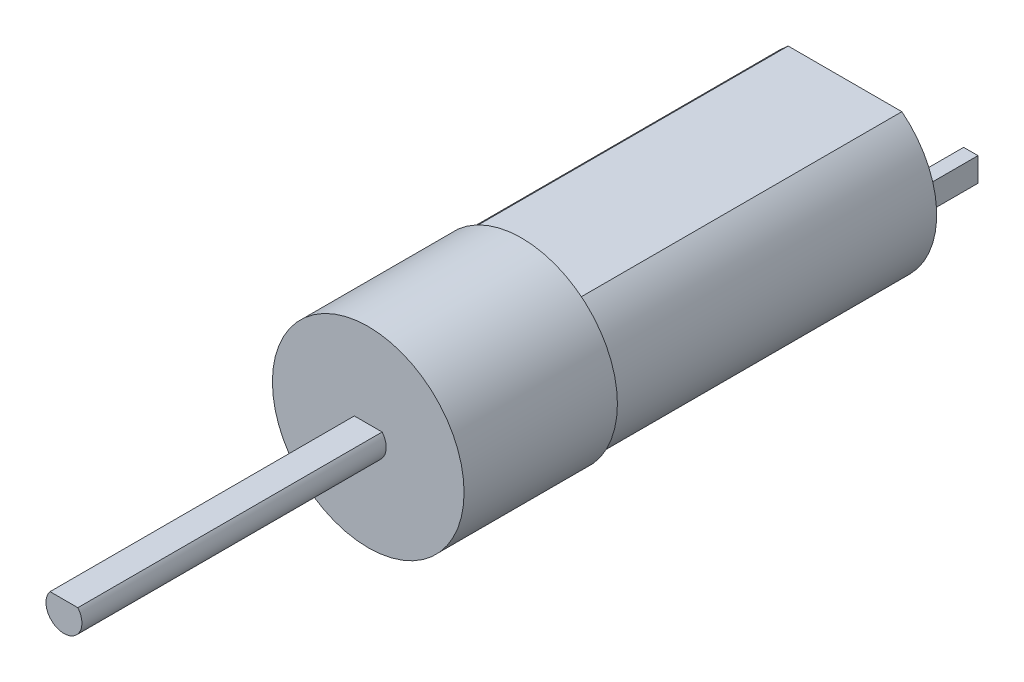
from build123d import *

# Parameters (mm, degrees)
SKETCH1_R           = 8
BOSS_EXTRUDE1_DEPTH = 12.8
SKETCH3_R           = 7.65
BOSS_EXTRUDE3_DEPTH = 27
CUT_EXTRUDE1_DEPTH  = 27
BOSS_EXTRUDE4_DEPTH = 25.4
SKETCH8_W           = 1.2
SKETCH8_H           = 2
BOSS_EXTRUDE5_DEPTH = 5


with BuildPart() as part:
    # Sketch1 → Boss-Extrude1 (new body)
    with BuildSketch(Plane.XY):
        Circle(SKETCH1_R)
    extrude(amount=BOSS_EXTRUDE1_DEPTH)

    # Sketch3 → Boss-Extrude3 (add)
    with BuildSketch(Plane(origin=(0, 0, 0), x_dir=(-1, 0, 0), z_dir=(0, 0, -1))):
        Circle(SKETCH3_R)
    extrude(amount=BOSS_EXTRUDE3_DEPTH)

    # Sketch4 → Cut-Extrude1 (cut)
    with BuildSketch(Plane(origin=(0, 0, -27), x_dir=(-1, 0, 0), z_dir=(0, 0, -1))):
        with BuildLine():
            Line((-4.745787606, -6), (4.745787606, -6))
            ThreePointArc((4.745787606, -6), (0, -7.65), (-4.745787606, -6))
        make_face()
        with BuildLine():
            Line((-4.745787606, 6), (4.745787606, 6))
            ThreePointArc((4.745787606, 6), (0, 7.65), (-4.745787606, 6))
        make_face()
    extrude(amount=-CUT_EXTRUDE1_DEPTH, mode=Mode.SUBTRACT)

    # Sketch7 → Boss-Extrude4 (add)
    with BuildSketch(Plane.XY.offset(12.8)):
        with BuildLine():
            Line((-1.160818677, 0.95), (1.160818677, 0.95))
            ThreePointArc((1.160818677, 0.95), (0, -1.5), (-1.160818677, 0.95))
        make_face()
    extrude(amount=BOSS_EXTRUDE4_DEPTH)

    # Sketch8 → Boss-Extrude5 (add)
    with BuildSketch(Plane(origin=(0, 0, -27), x_dir=(-1, 0, 0), z_dir=(0, 0, -1))):
        with Locations((-5.5, 0)):
            Rectangle(SKETCH8_W, SKETCH8_H)
        with Locations((5.5, 0)):
            Rectangle(SKETCH8_W, SKETCH8_H)
    extrude(amount=BOSS_EXTRUDE5_DEPTH)


solid = part.part
